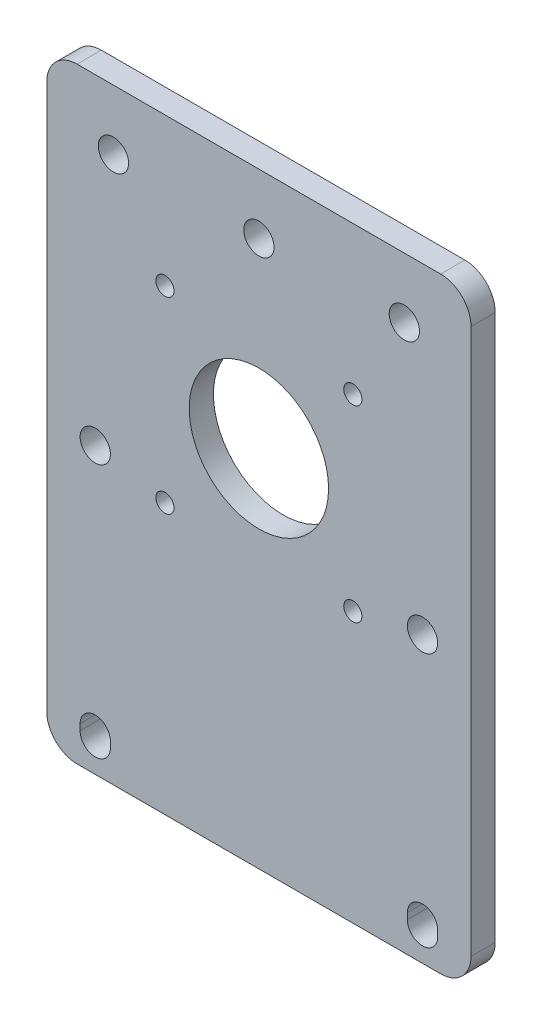
from build123d import *

# Parameters (mm, degrees)
SKETCH4_W           = 70
SKETCH4_H           = 100
SKETCH4_R           = 2.5
BOSS_EXTRUDE2_DEPTH = 4
SKETCH5_R           = 11.5
SKETCH5_R_2         = 1.5
CUT_EXTRUDE2_DEPTH  = 5
SKETCH6_R           = 2.5
CUT_EXTRUDE3_DEPTH  = 5
FILLET1_R           = 5


with BuildPart() as part:
    # Sketch4 → Boss-Extrude2 (new body)
    with BuildSketch(Plane.XY):
        Rectangle(SKETCH4_W, SKETCH4_H)
        with Locations((-27, -3)):
            Circle(SKETCH4_R, mode=Mode.SUBTRACT)
        with Locations((27, -3)):
            Circle(SKETCH4_R, mode=Mode.SUBTRACT)
        with BuildLine():
            Line((-24.5, -44), (-24.5, -45))
            ThreePointArc((-24.5, -45), (-27, -47.5), (-29.5, -45))
            Line((-29.5, -45), (-29.5, -44))
            ThreePointArc((-29.5, -44), (-27, -41.5), (-24.5, -44))
        make_face(mode=Mode.SUBTRACT)
        with BuildLine():
            Line((24.5, -44), (24.5, -45))
            ThreePointArc((24.5, -45), (27, -47.5), (29.5, -45))
            Line((29.5, -45), (29.5, -44))
            ThreePointArc((29.5, -44), (27, -41.5), (24.5, -44))
        make_face(mode=Mode.SUBTRACT)
    extrude(amount=BOSS_EXTRUDE2_DEPTH)

    # Sketch5 → Cut-Extrude2 (cut, through all)
    with BuildSketch(Plane.XY.offset(4)):
        with Locations((0, 10.076696831)):
            Circle(SKETCH5_R)
        with Locations((-15.5, 25.576696831)):
            Circle(SKETCH5_R_2)
        with Locations((15.5, 25.576696831)):
            Circle(SKETCH5_R_2)
        with Locations((15.5, -5.423303169)):
            Circle(SKETCH5_R_2)
        with Locations((-15.5, -5.423303169)):
            Circle(SKETCH5_R_2)
    extrude(amount=-CUT_EXTRUDE2_DEPTH, mode=Mode.SUBTRACT)

    # Sketch6 → Cut-Extrude3 (cut, through all)
    with BuildSketch(Plane.XY.offset(4)):
        with Locations((24, 40.076696831)):
            Circle(SKETCH6_R)
        with Locations((-24, 40.076696831)):
            Circle(SKETCH6_R)
        with Locations((0, 40.076696831)):
            Circle(SKETCH6_R)
    extrude(amount=-CUT_EXTRUDE3_DEPTH, mode=Mode.SUBTRACT)

    # Fillet1
    fillet1_edges = [part.edges().sort_by_distance(p)[0] for p in [
        (35, -50, 2),
        (-35, -50, 2),
        (-35, 50, 2),
        (35, 50, 2),
    ]]
    fillet(fillet1_edges, radius=FILLET1_R)


solid = part.part
